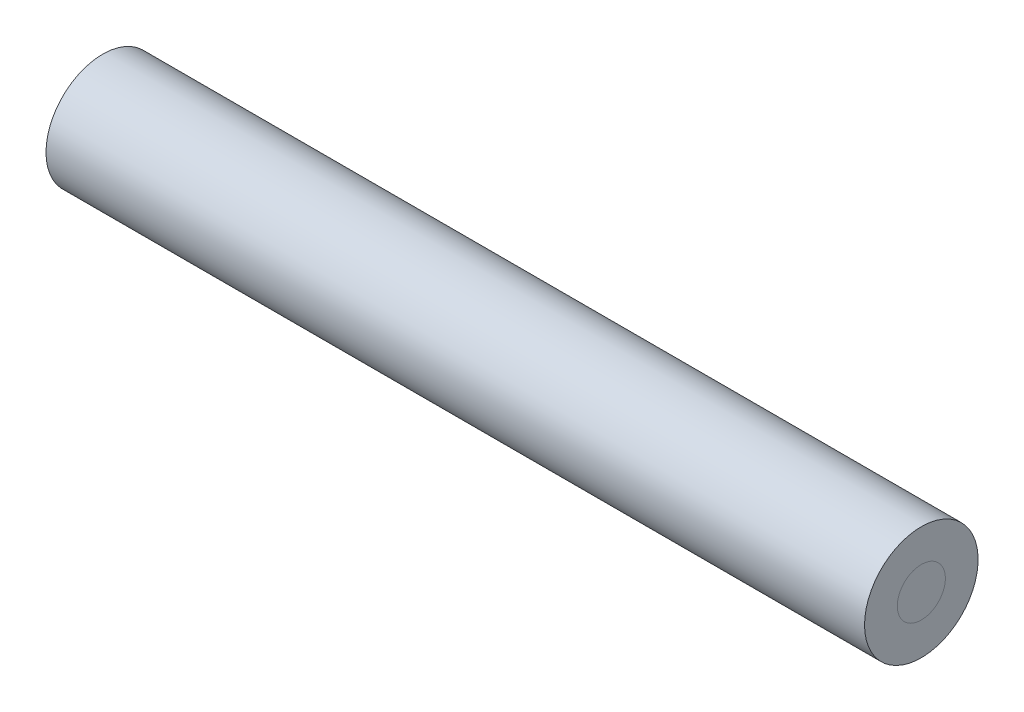
from build123d import *

# Parameters (mm, degrees)
SKETCH1_R           = 0.5969
BOSS_EXTRUDE1_DEPTH = 20.32
SKETCH1_3_R         = 1.4097
SKETCH1_3_R_2       = 0.5969
BOSS_EXTRUDE2_DEPTH = 20.32


with BuildPart() as part:
    # Sketch1 → Boss-Extrude1 (new body)
    with BuildSketch(Plane.ZY.offset(3.314620275)):
        with Locations((5.558825408, 54.574808677)):
            Circle(SKETCH1_R)
    extrude(amount=BOSS_EXTRUDE1_DEPTH)


with BuildPart() as body_2:
    # Sketch1_3 → Boss-Extrude2 (new body)
    with BuildSketch(Plane.ZY.offset(3.314620275)):
        with Locations((5.558825408, 54.574808677)):
            Circle(SKETCH1_3_R)
        with Locations((5.558825408, 54.574808677)):
            Circle(SKETCH1_3_R_2, mode=Mode.SUBTRACT)
    extrude(amount=BOSS_EXTRUDE2_DEPTH)


solid = Compound([part.part, body_2.part])
